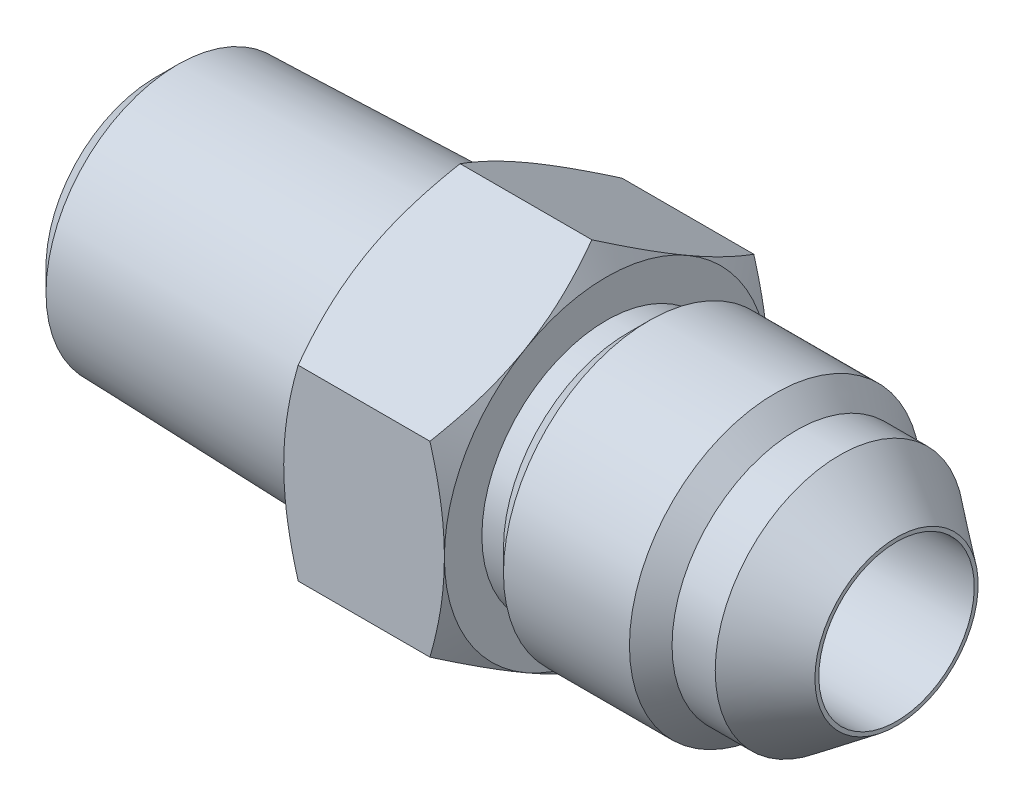
from build123d import *

# Parameters (mm, degrees)
SKETCH6_W           = 36.322
SKETCH6_H           = 7.14375
EXTRUDE1_DEPTH      = 7.874
SKETCH7_W           = 36.322
SKETCH7_H           = 3.81
SKETCH17_R          = 7.14375
CUT_EXTRUDE1_DEPTH  = 14.224
SKETCH19_R          = 6.858
BOSS_EXTRUDE1_DEPTH = 14.224
BOSS_EXTRUDE1_TAPER = 1.75
CHAMFER1_SIZE2      = 1.058333333
CHAMFER1_SIZE       = 1.092196811
SKETCH22_R          = 6.858
BOSS_EXTRUDE3_DEPTH = 14.224
BOSS_EXTRUDE3_TAPER = 15
SKETCH23_R          = 3.556
CUT_EXTRUDE2_DEPTH  = 14.224


with BuildPart() as part:
    # Sketch6 → Revolve3 (revolve)
    with BuildSketch(Plane.XY):
        with Locations((0, 3.571875)):
            Rectangle(SKETCH6_W, SKETCH6_H)
    revolve(axis=Axis((-18.161, 0, 0), (1, 0, 0)))

    # Sketch12 → Extrude1 (add)
    with BuildSketch(Plane(origin=(-3.937, 0, 0), x_dir=(0, 0, -1), z_dir=(1, 0, 0))):
        Polygon((0, 9.165435523), (-7.9375, 4.582717762), (-7.9375, -4.582717762), (0, -9.165435523), (7.9375, -4.582717762), (7.9375, 4.582717762), align=None)
    extrude(amount=EXTRUDE1_DEPTH)

    # Sketch10 → Cut-Revolve6 (revolve, cut)
    with BuildSketch(Plane.XY):
        Polygon((6.038876886, 7.14375), (3.937, 7.14375), (3.937, 6.100206448), (4.995333333, 6.100206448), align=None)
        Polygon((18.161, 7.14375), (12.214385213, 7.14375), (13.257928765, 6.100206448), (15.374595432, 6.100206448), (18.161, 4.0005), align=None)
    revolve(axis=Axis((-18.161, 0, 0), (1, 0, 0)), mode=Mode.SUBTRACT)

    # Sketch7 → Cut-Revolve5 (revolve, cut)
    with BuildSketch(Plane.XY):
        with Locations((0, 1.905)):
            Rectangle(SKETCH7_W, SKETCH7_H)
    revolve(axis=Axis((18.161, 0, 0), (-1, 0, 0)), mode=Mode.SUBTRACT)

    # Sketch13 → Cut-Revolve7 (revolve, cut)
    with BuildSketch(Plane.XY):
        Polygon((-3.937, 9.165435523), (-3.937, 7.9375), (-3.228051095, 9.165435523), align=None)
        Polygon((3.228051095, 9.165435523), (3.937, 7.9375), (3.937, 9.165435523), align=None)
    revolve(axis=Axis((-18.161, 0, 0), (1, 0, 0)), mode=Mode.SUBTRACT)

    # Sketch17 → Cut-Extrude1 (cut)
    with BuildSketch(Plane.ZY.offset(18.161)):
        Circle(SKETCH17_R)
    extrude(amount=-CUT_EXTRUDE1_DEPTH, mode=Mode.SUBTRACT)


with BuildPart() as body_2:
    # Sketch19 → Boss-Extrude1 (new body)
    with BuildSketch(Plane(origin=(-3.937, 0, 0), x_dir=(0, 0, -1), z_dir=(1, 0, 0))):
        Circle(SKETCH19_R)
    extrude(amount=-BOSS_EXTRUDE1_DEPTH, taper=BOSS_EXTRUDE1_TAPER)

    # Chamfer1
    chamfer1_edges = [body_2.edges().sort_by_distance(p)[0] for p in [
        (-18.161, 0, 6.423417495),
    ]]
    chamfer(chamfer1_edges, length=CHAMFER1_SIZE, length2=CHAMFER1_SIZE2)

    # Sketch22 → Boss-Extrude3 (add)
    with BuildSketch(Plane(origin=(-3.937, 0, 0), x_dir=(0, 0, -1), z_dir=(1, 0, 0))):
        Circle(SKETCH22_R)
    extrude(amount=-BOSS_EXTRUDE3_DEPTH, taper=BOSS_EXTRUDE3_TAPER)

    # Combine1: union part
    add(part.part)

    # Sketch23 → Cut-Extrude2 (cut)
    with BuildSketch(Plane.ZY.offset(18.161)):
        Circle(SKETCH23_R)
    extrude(amount=-CUT_EXTRUDE2_DEPTH, mode=Mode.SUBTRACT)


solid = body_2.part
